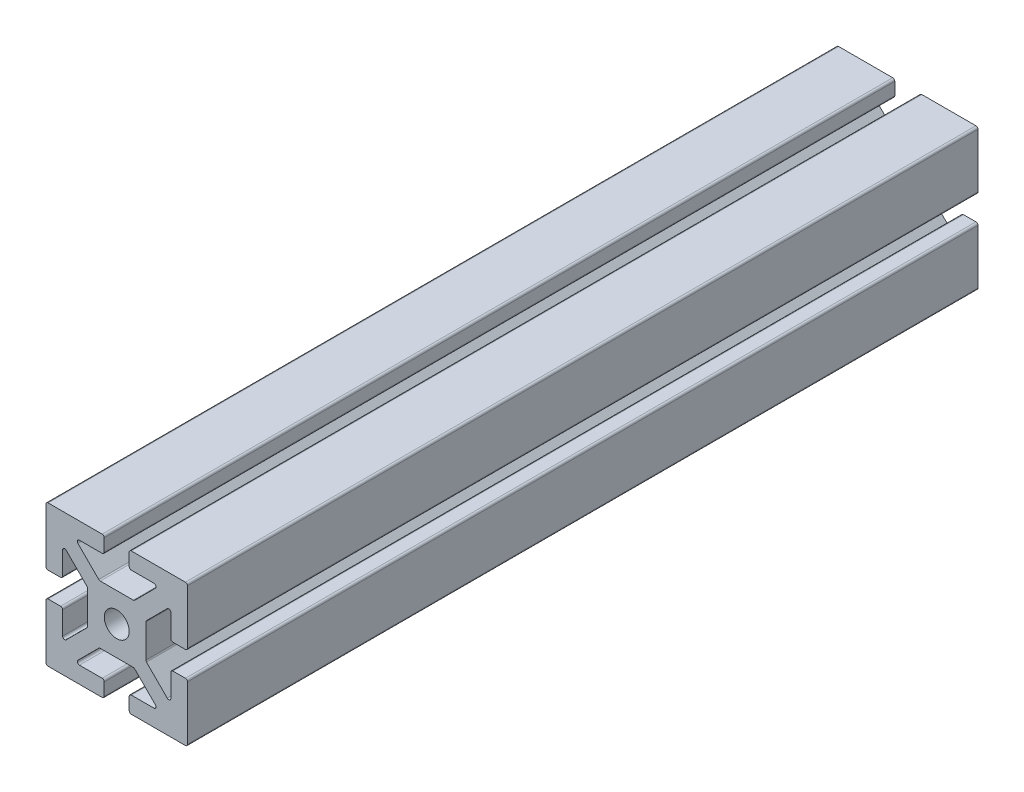
from build123d import *

# Parameters (mm, degrees)
SKETCH1_R           = 1.5
BOSS_EXTRUDE1_DEPTH = 95


with BuildPart() as part:
    # Sketch1 → Boss-Extrude1 (new body)
    with BuildSketch(Plane.XY):
        with BuildLine():
            Line((1.5, -8.25), (1.5, -6.75))
            ThreePointArc((1.5, -6.75), (1.573223305, -6.573223305), (1.75, -6.5))
            Line((1.75, -6.5), (4.482233047, -6.5))
            ThreePointArc((4.482233047, -6.5), (4.71320293, -6.345670858), (4.659009742, -6.073223305))
            Line((4.659009742, -6.073223305), (2.159009742, -3.573223305))
            ThreePointArc((2.159009742, -3.573223305), (2.077903905, -3.519030117), (1.982233047, -3.5))
            Line((1.982233047, -3.5), (-1.982233047, -3.5))
            ThreePointArc((-1.982233047, -3.5), (-2.077903905, -3.519030117), (-2.159009742, -3.573223305))
            Line((-2.159009742, -3.573223305), (-4.659009742, -6.073223305))
            ThreePointArc((-4.659009742, -6.073223305), (-4.71320293, -6.345670858), (-4.482233047, -6.5))
            Line((-4.482233047, -6.5), (-1.75, -6.5))
            ThreePointArc((-1.75, -6.5), (-1.573223305, -6.573223305), (-1.5, -6.75))
            Line((-1.5, -6.75), (-1.5, -8.25))
            ThreePointArc((-1.5, -8.25), (-1.573223305, -8.426776695), (-1.75, -8.5))
            Line((-1.75, -8.5), (-8.25, -8.5))
            ThreePointArc((-8.25, -8.5), (-8.426776695, -8.426776695), (-8.5, -8.25))
            Line((-8.5, -8.25), (-8.5, -1.75))
            ThreePointArc((-8.5, -1.75), (-8.426776695, -1.573223305), (-8.25, -1.5))
            Line((-8.25, -1.5), (-6.75, -1.5))
            ThreePointArc((-6.75, -1.5), (-6.573223305, -1.573223305), (-6.5, -1.75))
            Line((-6.5, -1.75), (-6.5, -4.482233047))
            ThreePointArc((-6.5, -4.482233047), (-6.345670858, -4.71320293), (-6.073223305, -4.659009742))
            Line((-6.073223305, -4.659009742), (-3.573223305, -2.159009742))
            ThreePointArc((-3.573223305, -2.159009742), (-3.519030117, -2.077903905), (-3.5, -1.982233047))
            Line((-3.5, -1.982233047), (-3.5, 1.982233047))
            ThreePointArc((-3.5, 1.982233047), (-3.519030117, 2.077903905), (-3.573223305, 2.159009742))
            Line((-3.573223305, 2.159009742), (-6.073223305, 4.659009742))
            ThreePointArc((-6.073223305, 4.659009742), (-6.345670858, 4.71320293), (-6.5, 4.482233047))
            Line((-6.5, 4.482233047), (-6.5, 1.75))
            ThreePointArc((-6.5, 1.75), (-6.573223305, 1.573223305), (-6.75, 1.5))
            Line((-6.75, 1.5), (-8.25, 1.5))
            ThreePointArc((-8.25, 1.5), (-8.426776695, 1.573223305), (-8.5, 1.75))
            Line((-8.5, 1.75), (-8.5, 8.25))
            ThreePointArc((-8.5, 8.25), (-8.426776695, 8.426776695), (-8.25, 8.5))
            Line((-8.25, 8.5), (-1.75, 8.5))
            ThreePointArc((-1.75, 8.5), (-1.573223305, 8.426776695), (-1.5, 8.25))
            Line((-1.5, 8.25), (-1.5, 6.75))
            ThreePointArc((-1.5, 6.75), (-1.573223305, 6.573223305), (-1.75, 6.5))
            Line((-1.75, 6.5), (-4.482233047, 6.5))
            ThreePointArc((-4.482233047, 6.5), (-4.71320293, 6.345670858), (-4.659009742, 6.073223305))
            Line((-4.659009742, 6.073223305), (-2.159009742, 3.573223305))
            ThreePointArc((-2.159009742, 3.573223305), (-2.077903905, 3.519030117), (-1.982233047, 3.5))
            Line((-1.982233047, 3.5), (1.982233047, 3.5))
            ThreePointArc((1.982233047, 3.5), (2.077903905, 3.519030117), (2.159009742, 3.573223305))
            Line((2.159009742, 3.573223305), (4.659009742, 6.073223305))
            ThreePointArc((4.659009742, 6.073223305), (4.71320293, 6.345670858), (4.482233047, 6.5))
            Line((4.482233047, 6.5), (1.75, 6.5))
            ThreePointArc((1.75, 6.5), (1.573223305, 6.573223305), (1.5, 6.75))
            Line((1.5, 6.75), (1.5, 8.25))
            ThreePointArc((1.5, 8.25), (1.573223305, 8.426776695), (1.75, 8.5))
            Line((1.75, 8.5), (8.25, 8.5))
            ThreePointArc((8.25, 8.5), (8.426776695, 8.426776695), (8.5, 8.25))
            Line((8.5, 8.25), (8.5, 1.75))
            ThreePointArc((8.5, 1.75), (8.426776695, 1.573223305), (8.25, 1.5))
            Line((8.25, 1.5), (6.75, 1.5))
            ThreePointArc((6.75, 1.5), (6.573223305, 1.573223305), (6.5, 1.75))
            Line((6.5, 1.75), (6.5, 4.482233047))
            ThreePointArc((6.5, 4.482233047), (6.345670858, 4.71320293), (6.073223305, 4.659009742))
            Line((6.073223305, 4.659009742), (3.573223305, 2.159009742))
            ThreePointArc((3.573223305, 2.159009742), (3.519030117, 2.077903905), (3.5, 1.982233047))
            Line((3.5, 1.982233047), (3.5, -1.982233047))
            ThreePointArc((3.5, -1.982233047), (3.519030117, -2.077903905), (3.573223305, -2.159009742))
            Line((3.573223305, -2.159009742), (6.073223305, -4.659009742))
            ThreePointArc((6.073223305, -4.659009742), (6.345670858, -4.71320293), (6.5, -4.482233047))
            Line((6.5, -4.482233047), (6.5, -1.75))
            ThreePointArc((6.5, -1.75), (6.573223305, -1.573223305), (6.75, -1.5))
            Line((6.75, -1.5), (8.25, -1.5))
            ThreePointArc((8.25, -1.5), (8.426776695, -1.573223305), (8.5, -1.75))
            Line((8.5, -1.75), (8.5, -8.25))
            ThreePointArc((8.5, -8.25), (8.426776695, -8.426776695), (8.25, -8.5))
            Line((8.25, -8.5), (1.75, -8.5))
            ThreePointArc((1.75, -8.5), (1.573223305, -8.426776695), (1.5, -8.25))
        make_face()
        Circle(SKETCH1_R, mode=Mode.SUBTRACT)
    extrude(amount=BOSS_EXTRUDE1_DEPTH)


solid = part.part
